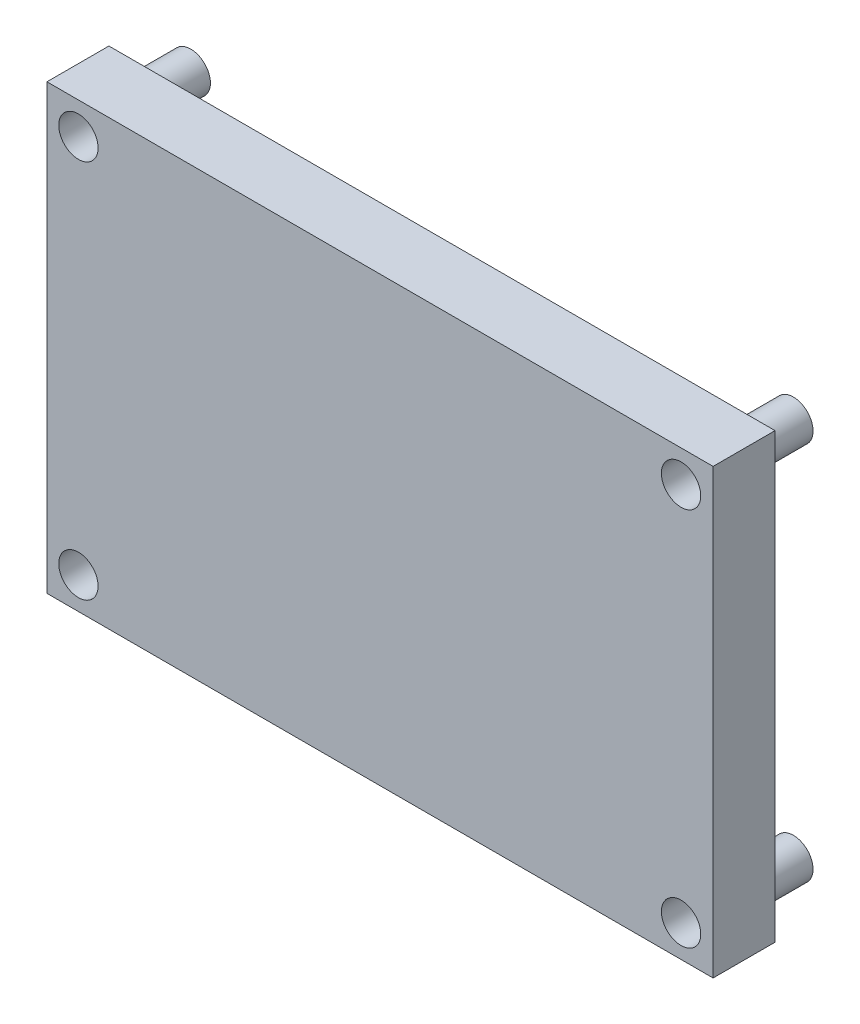
from build123d import *

# Parameters (mm, degrees)
SKETCH1_W             = 86
SKETCH1_H             = 57.2
SKETCH1_R             = 2.54
BOSS_EXTRUDE1_DEPTH   = 8
SKETCH1_2_R           = 2.54
BOSS_EXTRUDE2_DEPTH   = 6.5
BOSS_EXTRUDE2_2_DEPTH = 6.5
BOSS_EXTRUDE2_3_DEPTH = 6.5
BOSS_EXTRUDE2_4_DEPTH = 6.5


with BuildPart() as part:
    # Sketch1 → Boss-Extrude1 (new body)
    with BuildSketch(Plane.XY):
        with Locations((43, -28.6)):
            Rectangle(SKETCH1_W, SKETCH1_H)
        with Locations((4.064, -4.1)):
            Circle(SKETCH1_R, mode=Mode.SUBTRACT)
        with Locations((81.864, -4.1)):
            Circle(SKETCH1_R, mode=Mode.SUBTRACT)
        with Locations((81.864, -53.1)):
            Circle(SKETCH1_R, mode=Mode.SUBTRACT)
        with Locations((4.064, -53.1)):
            Circle(SKETCH1_R, mode=Mode.SUBTRACT)
    extrude(amount=BOSS_EXTRUDE1_DEPTH)


with BuildPart() as body_2:
    # Sketch1_2 → Boss-Extrude2 (new body)
    with BuildSketch(Plane.XY):
        with Locations((4.064, -4.1)):
            Circle(SKETCH1_2_R)
    extrude(amount=-BOSS_EXTRUDE2_DEPTH)


with BuildPart() as body_3:
    # Sketch1_2 → Boss-Extrude2 2 (new body)
    with BuildSketch(Plane.XY):
        with Locations((81.864, -4.1)):
            Circle(SKETCH1_2_R)
    extrude(amount=-BOSS_EXTRUDE2_2_DEPTH)


with BuildPart() as body_4:
    # Sketch1_2 → Boss-Extrude2 3 (new body)
    with BuildSketch(Plane.XY):
        with Locations((81.864, -53.1)):
            Circle(SKETCH1_2_R)
    extrude(amount=-BOSS_EXTRUDE2_3_DEPTH)


with BuildPart() as body_5:
    # Sketch1_2 → Boss-Extrude2 4 (new body)
    with BuildSketch(Plane.XY):
        with Locations((4.064, -53.1)):
            Circle(SKETCH1_2_R)
    extrude(amount=-BOSS_EXTRUDE2_4_DEPTH)


solid = Compound([part.part, body_2.part, body_3.part, body_4.part, body_5.part])
